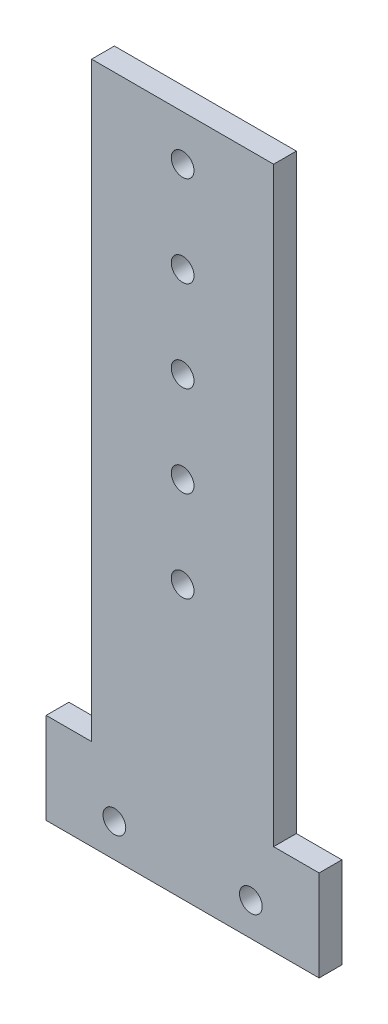
from build123d import *

# Parameters (mm, degrees)
SKETCH1_R           = 3.175
BOSS_EXTRUDE1_DEPTH = 6.35


with BuildPart() as part:
    # Sketch1 → Boss-Extrude1 (new body)
    with BuildSketch(Plane.XY):
        Polygon((0, 13.506188545), (0, 178.506188545), (50.8, 178.506188545), (50.8, 13.506188545), (63.5, 13.506188545), (63.5, -11.893811455), (-12.7, -11.893811455), (-12.7, 13.506188545), align=None)
        with Locations((6.35, -2.604847725)):
            Circle(SKETCH1_R, mode=Mode.SUBTRACT)
        with Locations((44.45, -2.604847725)):
            Circle(SKETCH1_R, mode=Mode.SUBTRACT)
        with Locations((25.4, 165.806188545)):
            Circle(SKETCH1_R, mode=Mode.SUBTRACT)
        with Locations((25.4, 140.406188545)):
            Circle(SKETCH1_R, mode=Mode.SUBTRACT)
        with Locations((25.4, 115.006188545)):
            Circle(SKETCH1_R, mode=Mode.SUBTRACT)
        with Locations((25.4, 89.606188545)):
            Circle(SKETCH1_R, mode=Mode.SUBTRACT)
        with Locations((25.4, 64.206188545)):
            Circle(SKETCH1_R, mode=Mode.SUBTRACT)
    extrude(amount=BOSS_EXTRUDE1_DEPTH)


solid = part.part
